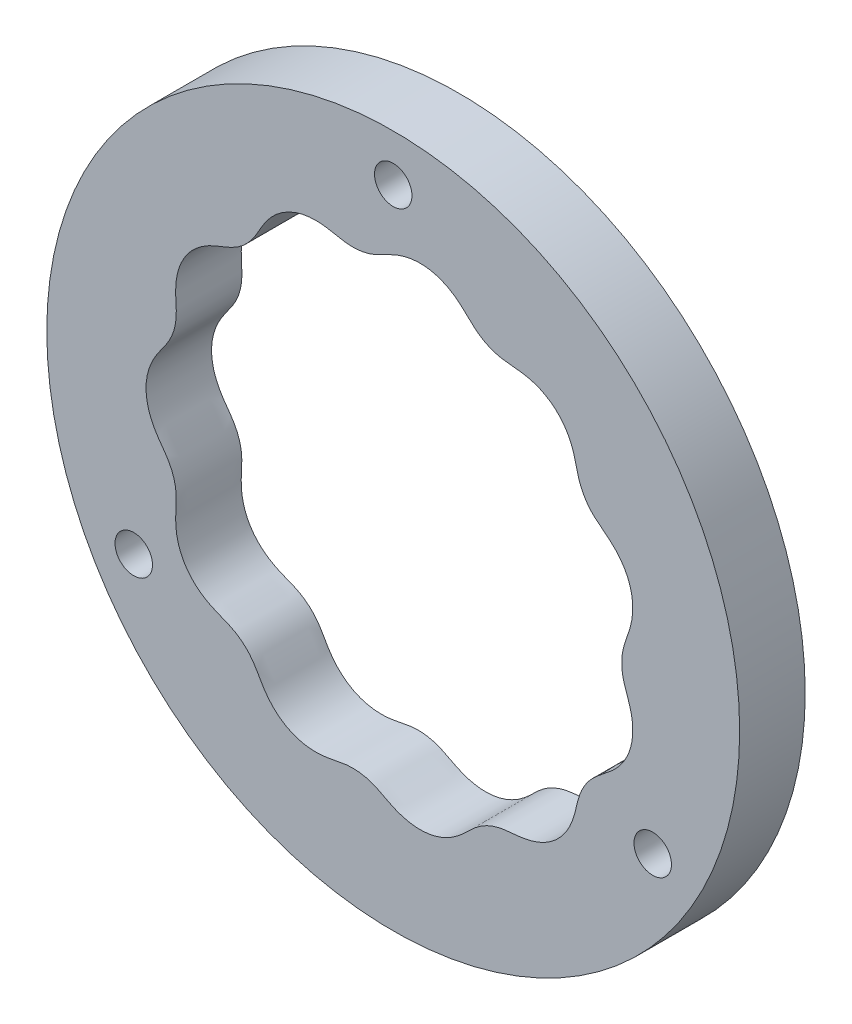
from build123d import *

# Parameters (mm, degrees)
SKETCH2_R           = 37
BOSS_EXTRUDE1_DEPTH = 7
CUT_EXTRUDE1_DEPTH  = 8
SKETCH4_R           = 2
CUT_EXTRUDE3_DEPTH  = 8.0000001
CIRPATTERN1_COUNT   = 3


with BuildPart() as part:
    # Sketch2 → Boss-Extrude1 (new body)
    with BuildSketch(Plane.XY):
        Circle(SKETCH2_R)
    extrude(amount=BOSS_EXTRUDE1_DEPTH)

    # Sketch3 → Cut-Extrude1 (cut, through all)
    with BuildSketch(Plane.XY):
        with BuildLine():
            add(Edge.make_bspline(
                [(-23.40819235, -6.886039026), (-23.288817541, -7.295764537), (-23.217034721, -7.709457125), (-23.155367476, -8.543669023), (-23.167756216, -8.964377815), (-23.212860746, -9.807489779), (-23.239086425, -10.229399388), (-23.230526706, -11.067067164), (-23.197706978, -11.483015559), (-23.09063538, -12.101090098), (-23.04551127, -12.306161172), (-22.93465442, -12.714219707), (-22.868421749, -12.918377244), (-22.639151049, -13.518921307), (-22.448413732, -13.897897224), (-21.991845991, -14.613463393), (-21.722475324, -14.952992516), (-21.128861932, -15.562397169), (-20.803854058, -15.835059918), (-20.276698229, -16.199014168), (-20.093910349, -16.312986304), (-19.721708311, -16.523677731), (-19.53167091, -16.620894398), (-18.951964145, -16.892730619), (-18.551774301, -17.045667836), (-17.755314402, -17.359525356), (-17.362256503, -17.526392072), (-16.804263957, -17.837399747), (-16.623140596, -17.950434528), (-16.271803624, -18.19746688), (-16.100721275, -18.332353914), (-15.618034349, -18.757856553), (-15.333625278, -19.072287697), (-14.828774296, -19.753790089), (-14.610868779, -20.123132291), (-14.186381358, -20.870234347), (-13.97502735, -21.244408936), (-13.497747293, -21.954510528), (-13.23375114, -22.291790125), (-12.785942836, -22.761394894), (-12.628260301, -22.911683025), (-12.30202211, -23.192834272), (-12.13272495, -23.324665946), (-11.781537955, -23.570506604), (-11.599672603, -23.68455024), (-11.223046422, -23.894386261), (-11.027078903, -23.990583066), (-10.43097633, -24.24547129), (-10.021361421, -24.372142946), (-9.178623735, -24.542231595), (-8.742538248, -24.584712471), (-7.884192602, -24.588427197), (-7.457709164, -24.55017086), (-6.608359323, -24.419708065), (-6.185661033, -24.325714089), (-5.338216401, -24.165637581), (-4.912882258, -24.105955124), (-4.269195469, -24.088234694), (-4.053758583, -24.09337352), (-3.620937414, -24.128244877), (-3.402331175, -24.158046898), (-2.763866229, -24.28220546), (-2.355588441, -24.411354891), (-1.566354851, -24.742620981), (-1.186175748, -24.946811928), (-0.422571811, -25.346525636), (-0.037789861, -25.537884231), (0.754822283, -25.852696863), (1.161945611, -25.978341625), (1.793037176, -26.106891127), (2.008035274, -26.139972758), (2.438847909, -26.183943804), (2.653795612, -26.194845075), (3.297283033, -26.194783323), (3.724470035, -26.15112654), (4.575077281, -25.972774314), (4.984640842, -25.840676222), (5.771312133, -25.497915928), (6.151615227, -25.284405785), (6.864774703, -24.794822528), (7.197580102, -24.518100814), (7.835593712, -23.929017006), (8.140584724, -23.617059415), (8.783268512, -23.03377866), (9.123537623, -22.765656788), (9.68150333, -22.422573433), (9.876583959, -22.316698234), (10.274754094, -22.129387288), (10.476609352, -22.04811652), (11.089927132, -21.83896116), (11.509580931, -21.747697352), (12.363584515, -21.630871168), (12.797686278, -21.604035964), (13.658224982, -21.516766691), (14.083457416, -21.454956148), (14.913670455, -21.258255581), (15.319115222, -21.125040501), (15.909953023, -20.862684273), (16.105273127, -20.764087573), (16.482400488, -20.548528307), (16.664099705, -20.431823491), (17.188945769, -20.055377913), (17.51241354, -19.7689083), (18.101230845, -19.125055492), (18.357405236, -18.778035412), (18.799157128, -18.037661536), (18.985250568, -17.640842305), (19.285873797, -16.826918848), (19.399954261, -16.408324346), (19.602792493, -15.563004959), (19.694513602, -15.137040873), (19.951049995, -14.310354353), (20.115126184, -13.909400554), (20.539968039, -13.140947229), (20.792508573, -12.786272464), (21.363351677, -12.142802946), (21.684667801, -11.85354298), (22.363949168, -11.308180499), (22.716967497, -11.048844136), (23.384256494, -10.489623919), (23.700062832, -10.1909478), (24.27471962, -9.532719245), (24.534742283, -9.171734254), (24.968428159, -8.415263861), (25.145981429, -8.016786182), (25.4172586, -7.176640982), (25.506442752, -6.748430099), (25.573427408, -6.098308226), (25.584638067, -5.880082638), (25.584744244, -5.440583938), (25.573522482, -5.21946973), (25.508668826, -4.566514261), (25.42353, -4.140000372), (25.191093099, -3.300011375), (25.041435865, -2.887041226), (24.749790273, -2.059530159), (24.614571054, -1.64331404), (24.482047889, -1.002675261), (24.448835274, -0.786585295), (24.406262024, -0.348870453), (24.397161176, -0.12530974), (24.408022813, 0.537617507), (24.465606162, 0.968760048), (24.664039981, 1.813166895), (24.807727544, 2.22582205), (25.100149127, 3.050048838), (25.242979977, 3.462901166), (25.458198903, 4.301530818), (25.533005781, 4.726901798), (25.598493216, 5.593175519), (25.588550653, 6.037984584), (25.47784252, 6.901933442), (25.37843899, 7.325540285), (25.160696452, 7.947912298), (25.076897237, 8.151895726), (24.890350992, 8.546419134), (24.787278878, 8.738017606), (24.561990109, 9.110150149), (24.439871782, 9.290741047), (24.176848108, 9.641065066), (24.035653869, 9.811121034), (23.592491731, 10.297839243), (23.268025214, 10.593087535), (22.585956886, 11.149715947), (22.228297385, 11.41043558), (21.550136327, 11.971199051), (21.231962813, 12.273706656), (20.808430397, 12.784328186), (20.674920686, 12.964502174), (20.429643875, 13.339515014), (20.319373155, 13.531563812), (20.023086437, 14.120390642), (19.873454772, 14.530531837), (19.637504636, 15.374067768), (19.548596402, 15.806511341), (19.332888928, 16.657481957), (19.205362972, 17.074881703), (18.876816854, 17.879156284), (18.676505451, 18.267882368), (18.194219875, 19.005148163), (17.919584441, 19.343412187), (17.303134206, 19.959026518), (16.956934348, 20.23864715), (16.223995889, 20.712888128), (15.835871279, 20.910089037), (15.222625963, 21.148637269), (15.012713547, 21.218490114), (14.591006131, 21.337475277), (14.37821074, 21.387070957), (13.734836107, 21.510431454), (13.298761295, 21.556202394), (12.423766522, 21.633163279), (11.985950736, 21.670001423), (11.127185424, 21.830673785), (10.703653659, 21.952980025), (9.885611879, 22.297911816), (9.505929653, 22.512667623), (8.798218841, 23.016634841), (8.472035802, 23.308506495), (7.837407475, 23.917817702), (7.524555089, 24.228396598), (6.858595146, 24.79734748), (6.506708016, 25.057370164), (5.939208038, 25.396099639), (5.742289678, 25.501114691), (5.340878576, 25.689456492), (5.136772265, 25.772709302), (4.514292729, 25.989847282), (4.084657964, 26.091420782), (3.201429594, 26.201814238), (2.761578071, 26.209151946), (1.885199254, 26.133569296), (1.444454398, 26.048636717), (0.599087248, 25.800631047), (0.191942, 25.637267196), (-0.602325727, 25.259818681), (-0.988964912, 25.044320825), (-1.775649228, 24.648264598), (-2.177843761, 24.473636646), (-3.018005873, 24.218942379), (-3.4608588, 24.136794252), (-4.336262079, 24.075640556), (-4.772573178, 24.095801866), (-5.643089858, 24.212950678), (-6.076928275, 24.310134058), (-6.945914179, 24.477114681), (-7.382101158, 24.544555259), (-8.042703178, 24.585823804), (-8.263899918, 24.590142951), (-8.708570333, 24.57720885), (-8.93287986, 24.559740407), (-9.594355635, 24.473842657), (-10.024537722, 24.372505017), (-10.65293989, 24.151663038), (-10.860814191, 24.065901502), (-11.263282853, 23.873865838), (-11.457912405, 23.767771394), (-12.022599234, 23.420192696), (-12.374814313, 23.14847089), (-13.023450636, 22.532554888), (-13.311032641, 22.196765096), (-13.828067731, 21.481146283), (-14.055834767, 21.100013809), (-14.495879776, 20.326126714), (-14.712720305, 19.936851735), (-15.218452898, 19.211093885), (-15.505895416, 18.873548932), (-16.001711946, 18.414602525), (-16.175976889, 18.271328134), (-16.53449708, 18.008911387), (-16.719832288, 17.888822577), (-17.292380572, 17.558834951), (-17.698179225, 17.382954187), (-18.523351825, 17.056040156), (-18.939461404, 16.898640298), (-19.737007282, 16.52455631), (-20.119650065, 16.310022758), (-20.660837866, 15.932359757), (-20.835883097, 15.797352579), (-21.17419497, 15.507263291), (-21.336684297, 15.352710544), (-21.793586318, 14.869812921), (-22.061874899, 14.51912944), (-22.40832954, 13.948781761), (-22.514574129, 13.750569889), (-22.70328577, 13.348505183), (-22.786492902, 13.143611193), (-22.931267448, 12.726327738), (-22.992903997, 12.513962219), (-23.095068043, 12.081919515), (-23.135668562, 11.861307713), (-23.225494952, 11.198249456), (-23.242351697, 10.753317954), (-23.22282216, 9.859883594), (-23.185449727, 9.412022235), (-23.158188152, 8.518267427), (-23.174030311, 8.072611506), (-23.277538617, 7.4074326), (-23.324940334, 7.185213951), (-23.446193278, 6.746321085), (-23.518769436, 6.533436301), (-23.769469726, 5.91288698), (-23.983101263, 5.524719786), (-24.471807105, 4.78212401), (-24.744866467, 4.426573905), (-25.254127502, 3.695295696), (-25.489169409, 3.319801049), (-25.885562981, 2.531736266), (-26.049145622, 2.117662896), (-26.288255564, 1.25647593), (-26.361609192, 0.820262987), (-26.415404394, -0.063463774), (-26.394333064, -0.515215593), (-26.259366709, -1.39068931), (-26.146404551, -1.818439017), (-25.832795732, -2.654682974), (-25.634356868, -3.054891842), (-25.178529194, -3.816258504), (-24.918547875, -4.178603578), (-24.395075199, -4.901412658), (-24.13847168, -5.265650047), (-23.816864796, -5.846941082), (-23.719651538, -6.046217799), (-23.590127723, -6.354126824), (-23.549708824, -6.458284064), (-23.493423172, -6.616916698), (-23.475349805, -6.670174242), (-23.449343014, -6.750669455), (-23.440845353, -6.777595718), (-23.424242593, -6.831664903), (-23.415653275, -6.860431182), (-23.40819235, -6.886039026)],
                knots=[0, 0, 0, 0, 0.0078125, 0.0078125, 0.015625, 0.015625, 0.0234375, 0.0234375, 0.03125, 0.03125, 0.03515625, 0.03515625, 0.0390625, 0.0390625, 0.046875, 0.046875, 0.0546875, 0.0546875, 0.0625, 0.0625, 0.06640625, 0.06640625, 0.0703125, 0.0703125, 0.078125, 0.078125, 0.0859375, 0.0859375, 0.08984375, 0.08984375, 0.09375, 0.09375, 0.1015625, 0.1015625, 0.109375, 0.109375, 0.1171875, 0.1171875, 0.125, 0.125, 0.12890625, 0.12890625, 0.1328125, 0.1328125, 0.13671875, 0.13671875, 0.140625, 0.140625, 0.1484375, 0.1484375, 0.15625, 0.15625, 0.1640625, 0.1640625, 0.171875, 0.171875, 0.1796875, 0.1796875, 0.18359375, 0.18359375, 0.1875, 0.1875, 0.1953125, 0.1953125, 0.203125, 0.203125, 0.2109375, 0.2109375, 0.21875, 0.21875, 0.22265625, 0.22265625, 0.2265625, 0.2265625, 0.234375, 0.234375, 0.2421875, 0.2421875, 0.25, 0.25, 0.2578125, 0.2578125, 0.265625, 0.265625, 0.2734375, 0.2734375, 0.27734375, 0.27734375, 0.28125, 0.28125, 0.2890625, 0.2890625, 0.296875, 0.296875, 0.3046875, 0.3046875, 0.3125, 0.3125, 0.31640625, 0.31640625, 0.3203125, 0.3203125, 0.328125, 0.328125, 0.3359375, 0.3359375, 0.34375, 0.34375, 0.3515625, 0.3515625, 0.359375, 0.359375, 0.3671875, 0.3671875, 0.375, 0.375, 0.3828125, 0.3828125, 0.390625, 0.390625, 0.3984375, 0.3984375, 0.40625, 0.40625, 0.4140625, 0.4140625, 0.421875, 0.421875, 0.42578125, 0.42578125, 0.4296875, 0.4296875, 0.4375, 0.4375, 0.4453125, 0.4453125, 0.453125, 0.453125, 0.45703125, 0.45703125, 0.4609375, 0.4609375, 0.46875, 0.46875, 0.4765625, 0.4765625, 0.484375, 0.484375, 0.4921875, 0.4921875, 0.5, 0.5, 0.5078125, 0.5078125, 0.51171875, 0.51171875, 0.515625, 0.515625, 0.51953125, 0.51953125, 0.5234375, 0.5234375, 0.53125, 0.53125, 0.5390625, 0.5390625, 0.546875, 0.546875, 0.55078125, 0.55078125, 0.5546875, 0.5546875, 0.5625, 0.5625, 0.5703125, 0.5703125, 0.578125, 0.578125, 0.5859375, 0.5859375, 0.59375, 0.59375, 0.6015625, 0.6015625, 0.609375, 0.609375, 0.61328125, 0.61328125, 0.6171875, 0.6171875, 0.625, 0.625, 0.6328125, 0.6328125, 0.640625, 0.640625, 0.6484375, 0.6484375, 0.65625, 0.65625, 0.6640625, 0.6640625, 0.671875, 0.671875, 0.67578125, 0.67578125, 0.6796875, 0.6796875, 0.6875, 0.6875, 0.6953125, 0.6953125, 0.703125, 0.703125, 0.7109375, 0.7109375, 0.71875, 0.71875, 0.7265625, 0.7265625, 0.734375, 0.734375, 0.7421875, 0.7421875, 0.75, 0.75, 0.7578125, 0.7578125, 0.76171875, 0.76171875, 0.765625, 0.765625, 0.7734375, 0.7734375, 0.77734375, 0.77734375, 0.78125, 0.78125, 0.7890625, 0.7890625, 0.796875, 0.796875, 0.8046875, 0.8046875, 0.8125, 0.8125, 0.8203125, 0.8203125, 0.82421875, 0.82421875, 0.828125, 0.828125, 0.8359375, 0.8359375, 0.84375, 0.84375, 0.8515625, 0.8515625, 0.85546875, 0.85546875, 0.859375, 0.859375, 0.8671875, 0.8671875, 0.87109375, 0.87109375, 0.875, 0.875, 0.87890625, 0.87890625, 0.8828125, 0.8828125, 0.890625, 0.890625, 0.8984375, 0.8984375, 0.90625, 0.90625, 0.91015625, 0.91015625, 0.9140625, 0.9140625, 0.921875, 0.921875, 0.9296875, 0.9296875, 0.9375, 0.9375, 0.9453125, 0.9453125, 0.953125, 0.953125, 0.9609375, 0.9609375, 0.96875, 0.96875, 0.9765625, 0.9765625, 0.984375, 0.984375, 0.9921875, 0.9921875, 0.99609375, 0.99609375, 0.998046875, 0.998046875, 0.999023438, 0.999023438, 0.999511719, 0.999511719, 1, 1, 1, 1], degree=3))
        make_face()
    extrude(amount=CUT_EXTRUDE1_DEPTH, mode=Mode.SUBTRACT)

    # Sketch4 → Cut-Extrude3 (cut, through all)
    with BuildSketch(Plane.XY):
        with Locations((0, 32)):
            Circle(SKETCH4_R)
    cut_extrude3 = extrude(amount=CUT_EXTRUDE3_DEPTH, mode=Mode.SUBTRACT)

    # CirPattern1: Cut-Extrude3 ×3 about axis
    cirpattern1_axis = Axis((0, 0, 0), (0, 0, 1))
    for i in range(1, CIRPATTERN1_COUNT):
        add(cut_extrude3.rotate(cirpattern1_axis, i * 360 / CIRPATTERN1_COUNT), mode=Mode.SUBTRACT)


solid = part.part
